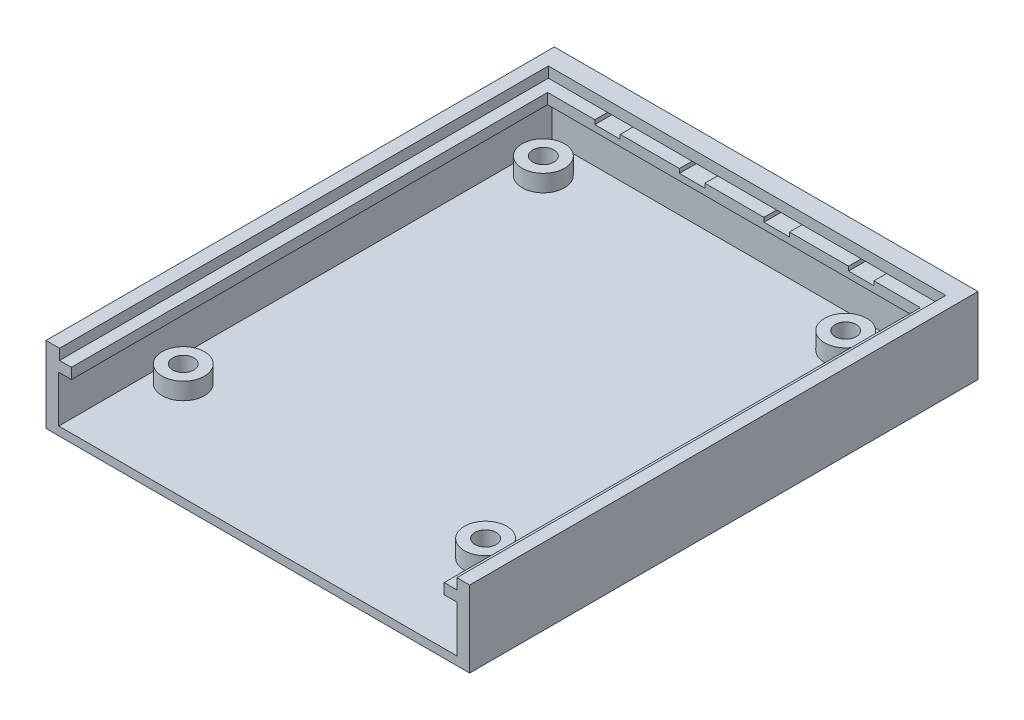
from build123d import *

# Parameters (mm, degrees)
SZKIC1_W                    = 100
SZKIC1_H                    = 120
DODANIE_WYCI_GNI_CIE3_DEPTH = 2
SZKIC3_R                    = 5
SZKIC3_R_2                  = 2.5
DODANIE_WYCI_GNI_CIE4_DEPTH = 4
DODANIE_WYCI_GNI_CIE5_DEPTH = 16
SZKIC6_W                    = 94
SZKIC6_H                    = 5
DODANIE_WYCI_GNI_CIE6_DEPTH = 4
SZKIC7_W                    = 112.4
SZKIC7_H                    = 5
DODANIE_WYCI_GNI_CIE7_DEPTH = 3
SZKIC8_W                    = 112.4
SZKIC8_H                    = 5
DODANIE_WYCI_GNI_CIE8_DEPTH = 3
WYTNIJ_WYCI_GNI_CIE1_DEPTH  = 2.5
SZKIC11_W                   = 6
SZKIC11_H                   = 3
SZKIC11_H_2                 = 2.6
WYTNIJ_WYCI_GNI_CIE3_DEPTH  = 1


with BuildPart() as part:
    # Szkic1 → Dodanie-wyciągnięcie3 (new body)
    with BuildSketch(Plane(origin=(0, 0, 0), x_dir=(1, 0, 0), z_dir=(0, 1, 0))):
        with Locations((-26.162790698, -20.11627907)):
            Rectangle(SZKIC1_W, SZKIC1_H)
    extrude(amount=DODANIE_WYCI_GNI_CIE3_DEPTH)

    # Szkic3 → Dodanie-wyciągnięcie4 (add)
    with BuildSketch(Plane(origin=(0, 2, 0), x_dir=(1, 0, 0), z_dir=(0, 1, 0))):
        with Locations((-67.162790698, 28.28372093)):
            Circle(SZKIC3_R)
        with Locations((-67.162790698, 28.28372093)):
            Circle(SZKIC3_R_2, mode=Mode.SUBTRACT)
        with Locations((4.207209302, 28.28372093)):
            Circle(SZKIC3_R)
        with Locations((4.207209302, 28.28372093)):
            Circle(SZKIC3_R_2, mode=Mode.SUBTRACT)
        with Locations((4.207209302, -56.71627907)):
            Circle(SZKIC3_R)
        with Locations((4.207209302, -56.71627907)):
            Circle(SZKIC3_R_2, mode=Mode.SUBTRACT)
        with Locations((-67.162790698, -56.71627907)):
            Circle(SZKIC3_R)
        with Locations((-67.162790698, -56.71627907)):
            Circle(SZKIC3_R_2, mode=Mode.SUBTRACT)
    extrude(amount=DODANIE_WYCI_GNI_CIE4_DEPTH)

    # Szkic4 → Dodanie-wyciągnięcie5 (add)
    with BuildSketch(Plane(origin=(0, 2, 0), x_dir=(1, 0, 0), z_dir=(0, 1, 0))):
        Polygon((-76.162790698, 39.88372093), (-76.162790698, -80.11627907), (-73.162790698, -80.11627907), (-73.162790698, -76.51627907), (-73.162790698, 36.28372093), (20.837209302, 36.28372093), (20.837209302, -76.51627907), (20.837209302, -80.11627907), (23.837209302, -80.11627907), (23.837209302, 39.88372093), align=None)
    extrude(amount=DODANIE_WYCI_GNI_CIE5_DEPTH)

    # Szkic6 → Dodanie-wyciągnięcie6 (add)
    with BuildSketch(Plane.XY.offset(-36.28372093)):
        with Locations((-26.162790698, 15.5)):
            Rectangle(SZKIC6_W, SZKIC6_H)
    extrude(amount=DODANIE_WYCI_GNI_CIE6_DEPTH)

    # Szkic7 → Dodanie-wyciągnięcie7 (add)
    with BuildSketch(Plane.ZY.offset(-20.837209302)):
        with Locations((23.91627907, 15.5)):
            Rectangle(SZKIC7_W, SZKIC7_H)
    extrude(amount=DODANIE_WYCI_GNI_CIE7_DEPTH)

    # Szkic8 → Dodanie-wyciągnięcie8 (add)
    with BuildSketch(Plane(origin=(-73.162790698, 0, 0), x_dir=(0, 0, -1), z_dir=(1, 0, 0))):
        with Locations((-23.91627907, 15.5)):
            Rectangle(SZKIC8_W, SZKIC8_H)
    extrude(amount=DODANIE_WYCI_GNI_CIE8_DEPTH)

    # Szkic10 → Wytnij-wyciągnięcie1 (cut)
    with BuildSketch(Plane(origin=(0, 18, 0), x_dir=(1, 0, 0), z_dir=(0, 1, 0))):
        Polygon((-70.162790698, -80.11627907), (-72.972722391, -80.11627907), (-72.972722391, 35.28372093), (20.837209302, 35.28372093), (20.837209302, -80.11627907), (17.837209302, -80.11627907), (17.837209302, 32.28372093), (-70.162790698, 32.28372093), align=None)
    extrude(amount=-WYTNIJ_WYCI_GNI_CIE1_DEPTH, mode=Mode.SUBTRACT)

    # Szkic11 → Wytnij-wyciągnięcie3 (cut)
    with BuildSketch(Plane(origin=(0, 15.5, 0), x_dir=(1, 0, 0), z_dir=(0, 1, 0))):
        with Locations((-56.010736052, 33.78372093)):
            Rectangle(SZKIC11_W, SZKIC11_H)
        with Locations((-56.010736052, 36.58372093)):
            Rectangle(SZKIC11_W, SZKIC11_H_2)
        with Locations((-36.048749714, 33.78372093)):
            Rectangle(SZKIC11_W, SZKIC11_H)
        with Locations((-36.048749714, 36.58372093)):
            Rectangle(SZKIC11_W, SZKIC11_H_2)
        with Locations((-16.086763375, 33.78372093)):
            Rectangle(SZKIC11_W, SZKIC11_H)
        with Locations((-16.086763375, 36.58372093)):
            Rectangle(SZKIC11_W, SZKIC11_H_2)
        with Locations((3.875222964, 33.78372093)):
            Rectangle(SZKIC11_W, SZKIC11_H)
        with Locations((3.875222964, 36.58372093)):
            Rectangle(SZKIC11_W, SZKIC11_H_2)
    extrude(amount=-WYTNIJ_WYCI_GNI_CIE3_DEPTH, mode=Mode.SUBTRACT)


solid = part.part
